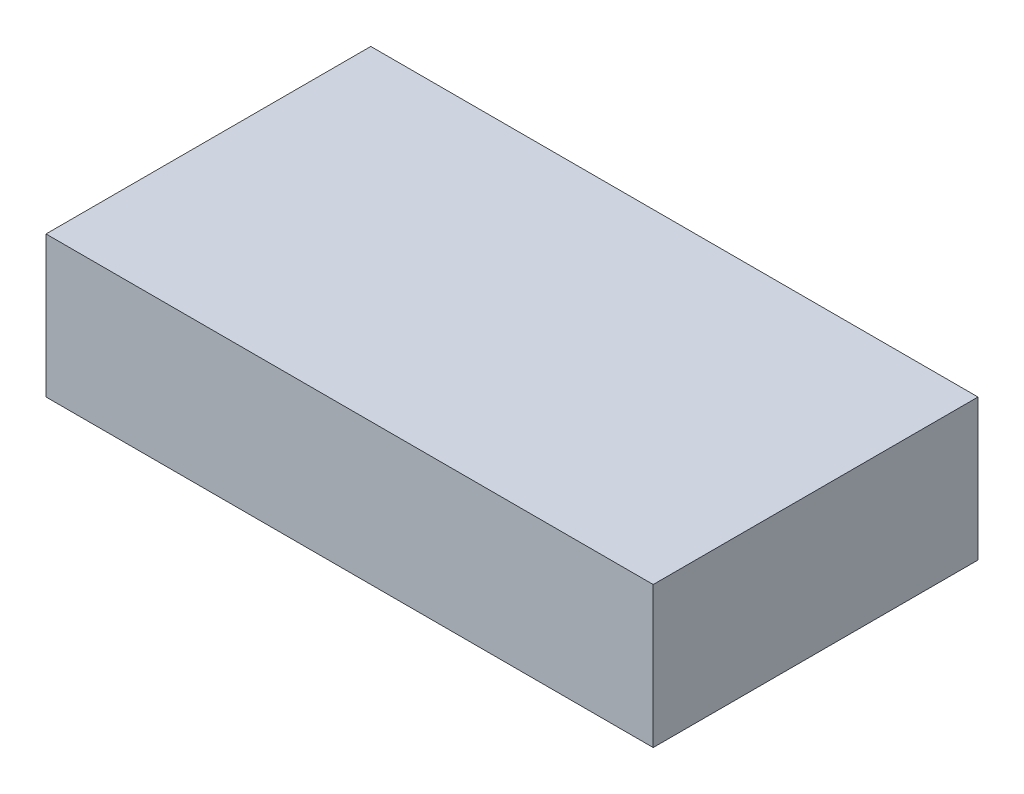
from build123d import *

# Parameters (mm, degrees)
SKETCH1_W           = 215
SKETCH1_H           = 115
BOSS_EXTRUDE1_DEPTH = 50


with BuildPart() as part:
    # Sketch1 → Boss-Extrude1 (new body)
    with BuildSketch(Plane(origin=(0, 0, 0), x_dir=(1, 0, 0), z_dir=(0, 1, 0))):
        Rectangle(SKETCH1_W, SKETCH1_H)
    extrude(amount=BOSS_EXTRUDE1_DEPTH)


solid = part.part
